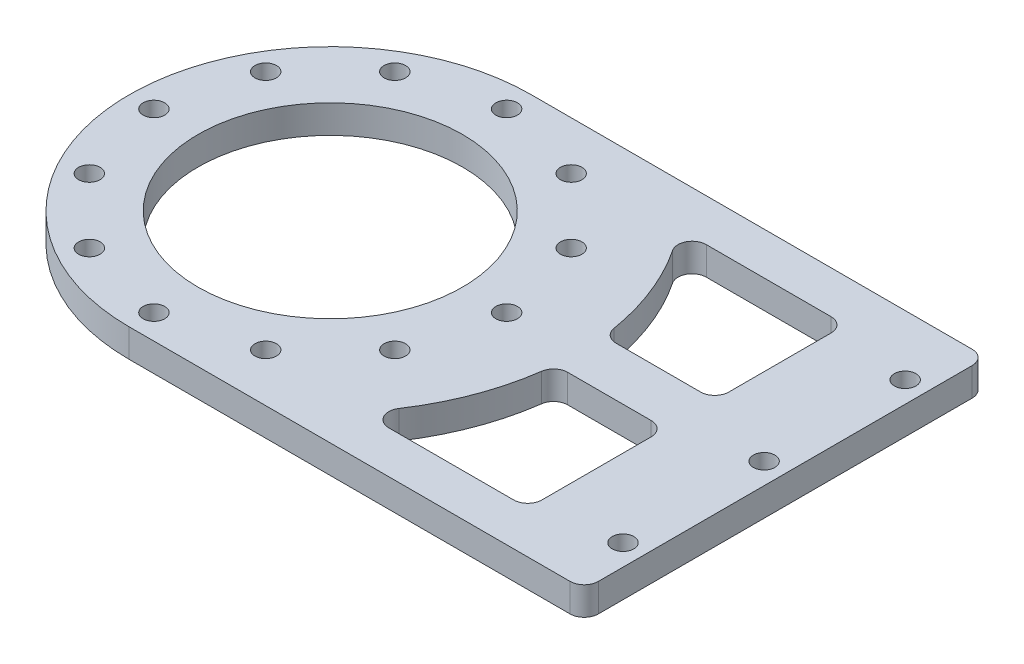
from build123d import *

# Parameters (mm, degrees)
EXTRUDE_1_DEPTH     = 4
SKETCH_2_R          = 1.525
CUT_EXTRUDE_1_DEPTH = 5
SKETCH_4_R          = 10
CUT_EXTRUDE_2_DEPTH = 5
SKETCH_7_R          = 18.75
CUT_EXTRUDE_4_DEPTH = 5
SKETCH_8_R          = 1.525
CUT_EXTRUDE_5_DEPTH = 5
SKETCH_9_R          = 1.525
CUT_EXTRUDE_6_DEPTH = 5
FILLET_1_R          = 2
CUT_EXTRUDE_8_DEPTH = 5
FILLET_2_R          = 2


with BuildPart() as part:
    # 草图1 → 凸台-拉伸1 (new body)
    with BuildSketch(Plane(origin=(0, 0, 0), x_dir=(1, 0, 0), z_dir=(0, 1, 0))):
        with BuildLine():
            ThreePointArc((-32.25, 28.5), (-60.75, 0), (-32.25, -28.5))
            Line((-32.25, -28.5), (-32.25, 28.5))
        make_face()
        with BuildLine():
            Line((-32.25, 28.5), (-32.25, -28.5))
            ThreePointArc((-32.25, -28.5), (-12.097456736, -20.152543264), (-3.75, 0))
            ThreePointArc((-3.75, 0), (-12.097456736, 20.152543264), (-32.25, 28.5))
        make_face()
        with BuildLine():
            ThreePointArc((-3.75, 0), (-12.097456736, -20.152543264), (-32.25, -28.5))
            Line((-32.25, -28.5), (32.25, -28.5))
            Line((32.25, -28.5), (32.25, 28.5))
            Line((32.25, 28.5), (-32.25, 28.5))
            ThreePointArc((-32.25, 28.5), (-12.097456736, 20.152543264), (-3.75, 0))
        make_face()
    extrude(amount=EXTRUDE_1_DEPTH)

    # 草图2 → 切除-拉伸1 (cut, through all)
    with BuildSketch(Plane(origin=(0, 4, 0), x_dir=(1, 0, 0), z_dir=(0, 1, 0))):
        with Locations((-45.75, 0)):
            Circle(SKETCH_2_R)
        with Locations((-39, 11.691342951)):
            Circle(SKETCH_2_R)
        with Locations((-25.5, 11.691342951)):
            Circle(SKETCH_2_R)
        with Locations((-18.75, 0)):
            Circle(SKETCH_2_R)
        with Locations((-25.5, -11.691342951)):
            Circle(SKETCH_2_R)
        with Locations((-39, -11.691342951)):
            Circle(SKETCH_2_R)
    extrude(amount=-CUT_EXTRUDE_1_DEPTH, mode=Mode.SUBTRACT)

    # 草图4 → 切除-拉伸2 (cut, through all)
    with BuildSketch(Plane(origin=(0, 4, 0), x_dir=(1, 0, 0), z_dir=(0, 1, 0))):
        with Locations((-32.25, 0)):
            Circle(SKETCH_4_R)
    extrude(amount=-CUT_EXTRUDE_2_DEPTH, mode=Mode.SUBTRACT)

    # 草图7 → 切除-拉伸4 (cut, through all)
    with BuildSketch(Plane(origin=(0, 4, 0), x_dir=(1, 0, 0), z_dir=(0, 1, 0))):
        with Locations((-32.25, 0)):
            Circle(SKETCH_7_R)
    extrude(amount=-CUT_EXTRUDE_4_DEPTH, mode=Mode.SUBTRACT)

    # 草图8 → 切除-拉伸5 (cut, through all)
    with BuildSketch(Plane(origin=(0, 4, 0), x_dir=(1, 0, 0), z_dir=(0, 1, 0))):
        with Locations((-32.25, 25)):
            Circle(SKETCH_8_R)
        with Locations((-19.75, 21.650635095)):
            Circle(SKETCH_8_R)
        with Locations((-10.599364905, 12.5)):
            Circle(SKETCH_8_R)
        with Locations((-7.25, 0)):
            Circle(SKETCH_8_R)
        with Locations((-10.599364905, -12.5)):
            Circle(SKETCH_8_R)
        with Locations((-19.75, -21.650635095)):
            Circle(SKETCH_8_R)
        with Locations((-32.25, -25)):
            Circle(SKETCH_8_R)
        with Locations((-44.75, -21.650635095)):
            Circle(SKETCH_8_R)
        with Locations((-53.900635095, -12.5)):
            Circle(SKETCH_8_R)
        with Locations((-57.25, 0)):
            Circle(SKETCH_8_R)
        with Locations((-53.900635095, 12.5)):
            Circle(SKETCH_8_R)
        with Locations((-44.75, 21.650635095)):
            Circle(SKETCH_8_R)
    extrude(amount=-CUT_EXTRUDE_5_DEPTH, mode=Mode.SUBTRACT)

    # 草图9 → 切除-拉伸6 (cut, through all)
    with BuildSketch(Plane(origin=(0, 4, 0), x_dir=(1, 0, 0), z_dir=(0, 1, 0))):
        with Locations((29.25, 0)):
            Circle(SKETCH_9_R)
        with Locations((29.25, 20)):
            Circle(SKETCH_9_R)
        with Locations((29.25, -20)):
            Circle(SKETCH_9_R)
    extrude(amount=-CUT_EXTRUDE_6_DEPTH, mode=Mode.SUBTRACT)

    # 圆角1
    fillet_1_edges = [part.edges().sort_by_distance(p)[0] for p in [
        (32.25, 2, -28.5),
        (32.25, 2, 28.5),
    ]]
    fillet(fillet_1_edges, radius=FILLET_1_R)

    # 草图18 → 切除-拉伸8 (cut, through all)
    with BuildSketch(Plane(origin=(0, 4, 0), x_dir=(1, 0, 0), z_dir=(0, 1, 0))):
        with BuildLine():
            Line((18.25, 22.5), (-5.440486763, 22.5))
            ThreePointArc((-5.440486763, 22.5), (-0.100467085, 13.835011143), (2.520677301, 4))
            Line((2.520677301, 4), (18.25, 4))
            Line((18.25, 4), (18.25, 22.5))
        make_face()
        with BuildLine():
            Line((-5.440486763, -22.5), (18.25, -22.5))
            Line((18.25, -22.5), (18.25, -3))
            Line((18.25, -3), (2.621191548, -3))
            ThreePointArc((2.621191548, -3), (0.094857948, -13.371991785), (-5.440486763, -22.5))
        make_face()
    extrude(amount=-CUT_EXTRUDE_8_DEPTH, mode=Mode.SUBTRACT)

    # 圆角2
    fillet_2_edges = [part.edges().sort_by_distance(p)[0] for p in [
        (2.520677301, 2, -4),
        (-5.440486763, 2, -22.5),
        (18.25, 2, -22.5),
        (18.25, 2, -4),
        (-5.440486763, 2, 22.5),
        (2.621191548, 2, 3),
        (18.25, 2, 3),
        (18.25, 2, 22.5),
    ]]
    fillet(fillet_2_edges, radius=FILLET_2_R)


solid = part.part
